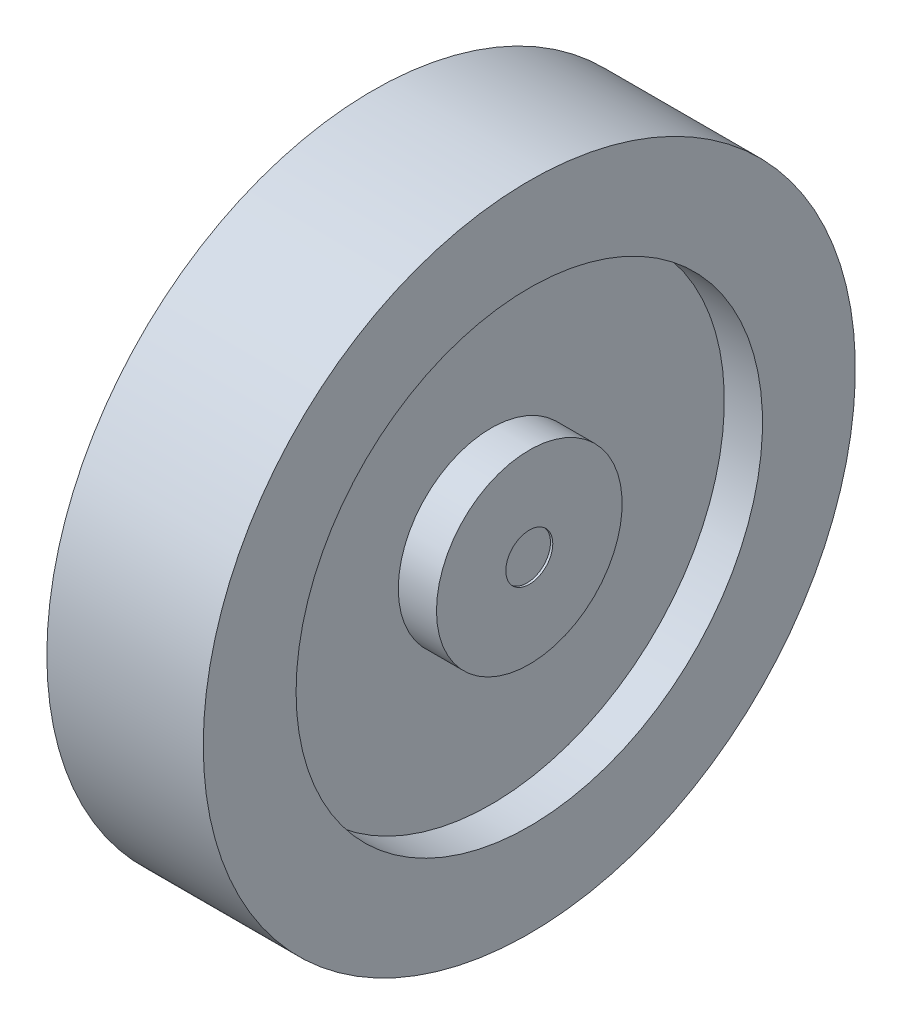
from build123d import *

# Parameters (mm, degrees)
SKETCH2_R          = 2.571129816
CUT_EXTRUDE2_DEPTH = 25.4


with BuildPart() as part:
    # Sketch1 → Revolve-Thin3 (revolve)
    with BuildSketch(Plane.XY):
        Polygon((0.497679461, 0), (8.560086725, 0), (8.560086725, 10.16), (4.379579254, 10.16), (4.379579254, 25.527), (8.560086725, 25.527), (8.560086725, 35.687), (-8.560086725, 35.687), (-8.560086725, 25.527), (-4.379579254, 25.527), (-4.379579254, 10.16), (-8.560086725, 10.16), (-8.560086725, 0), (-0.497679461, 0), (-0.497679461, 0.254), (-8.306086725, 0.254), (-8.306086725, 9.906), (-4.125579254, 9.906), (-4.125579254, 25.781), (-8.306086725, 25.781), (-8.306086725, 35.433), (8.306086725, 35.433), (8.306086725, 25.781), (4.125579254, 25.781), (4.125579254, 9.906), (8.306086725, 9.906), (8.306086725, 0.254), (0.497679461, 0.254), align=None)
    revolve(axis=Axis((-8.560086725, 0, 0), (1, 0, 0)))

    # Sketch2 → Cut-Extrude2 (cut)
    with BuildSketch(Plane.ZY.offset(8.560086725)):
        Circle(SKETCH2_R)
    extrude(amount=-CUT_EXTRUDE2_DEPTH, mode=Mode.SUBTRACT)


solid = part.part
